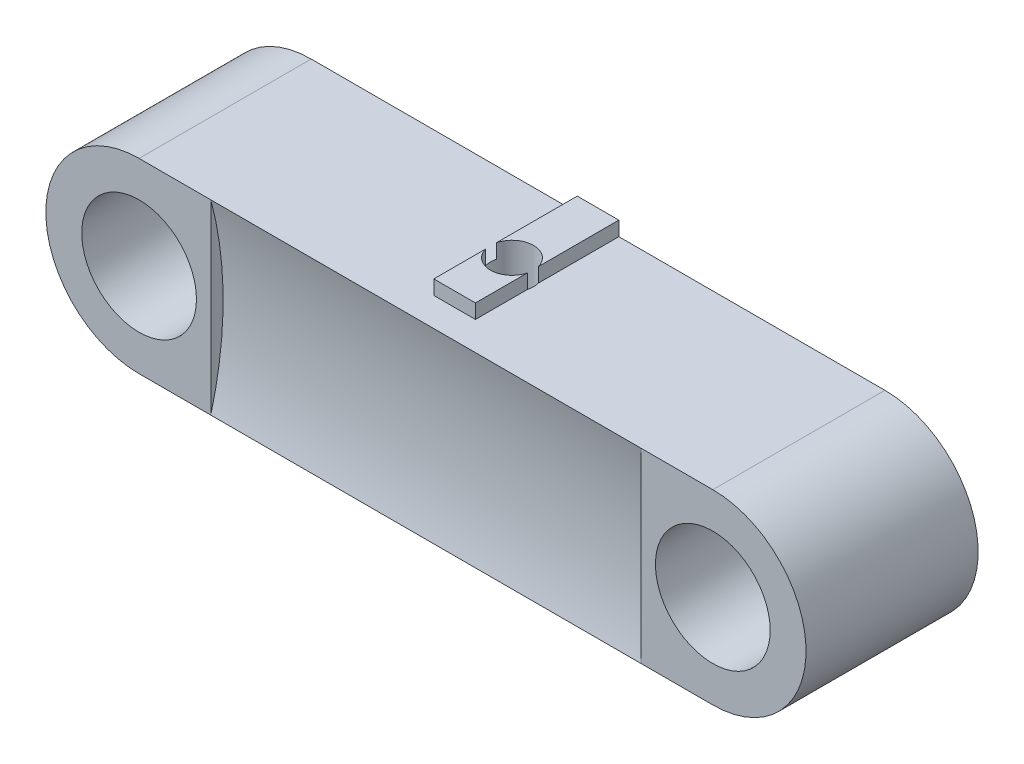
from build123d import *

# Parameters (mm, degrees)
SKETCH1_R             = 4
MAIN_DEPTH            = 6
SCREWBALLDRIVER_DEPTH = 15
SKETCH3_W             = 2.9
SKETCH3_H             = 10
MAKERBEAMRAIL_DEPTH   = 7.5
SKETCH4_R             = 1.5
MAKERBEAMHOLE_DEPTH   = 15


with BuildPart() as part:
    # Sketch1 → Main (new body, symmetric)
    with BuildSketch(Plane.XY):
        with BuildLine():
            Line((-20, 6.5), (20, 6.5))
            ThreePointArc((20, 6.5), (26.5, 0), (20, -6.5))
            Line((20, -6.5), (-20, -6.5))
            ThreePointArc((-20, -6.5), (-26.5, 0), (-20, 6.5))
        make_face()
        with Locations((-20, 0)):
            Circle(SKETCH1_R, mode=Mode.SUBTRACT)
        with Locations((20, 0)):
            Circle(SKETCH1_R, mode=Mode.SUBTRACT)
    extrude(amount=MAIN_DEPTH, both=True)

    # Sketch2 → ScrewBallDriver (cut, symmetric)
    with BuildSketch(Plane(origin=(0, 0, 0), x_dir=(0, 0, -1), z_dir=(1, 0, 0))):
        with BuildLine():
            Line((-6, 6.5), (-6, -6.5))
            ThreePointArc((-6, -6.5), (-5.140215409, 0), (-6, 6.5))
        make_face()
    extrude(amount=SCREWBALLDRIVER_DEPTH, both=True, mode=Mode.SUBTRACT)

    # Sketch3 → MakerBeamRail (add)
    with BuildSketch(Plane(origin=(0, 0, 0), x_dir=(1, 0, 0), z_dir=(0, 1, 0))):
        with Locations((0, 1)):
            Rectangle(SKETCH3_W, SKETCH3_H)
    extrude(amount=MAKERBEAMRAIL_DEPTH)

    # Sketch4 → MakerBeamHole (cut, through all)
    with BuildSketch(Plane(origin=(0, 7.5, 0), x_dir=(1, 0, 0), z_dir=(0, 1, 0))):
        Circle(SKETCH4_R)
    extrude(amount=-MAKERBEAMHOLE_DEPTH, mode=Mode.SUBTRACT)


solid = part.part
